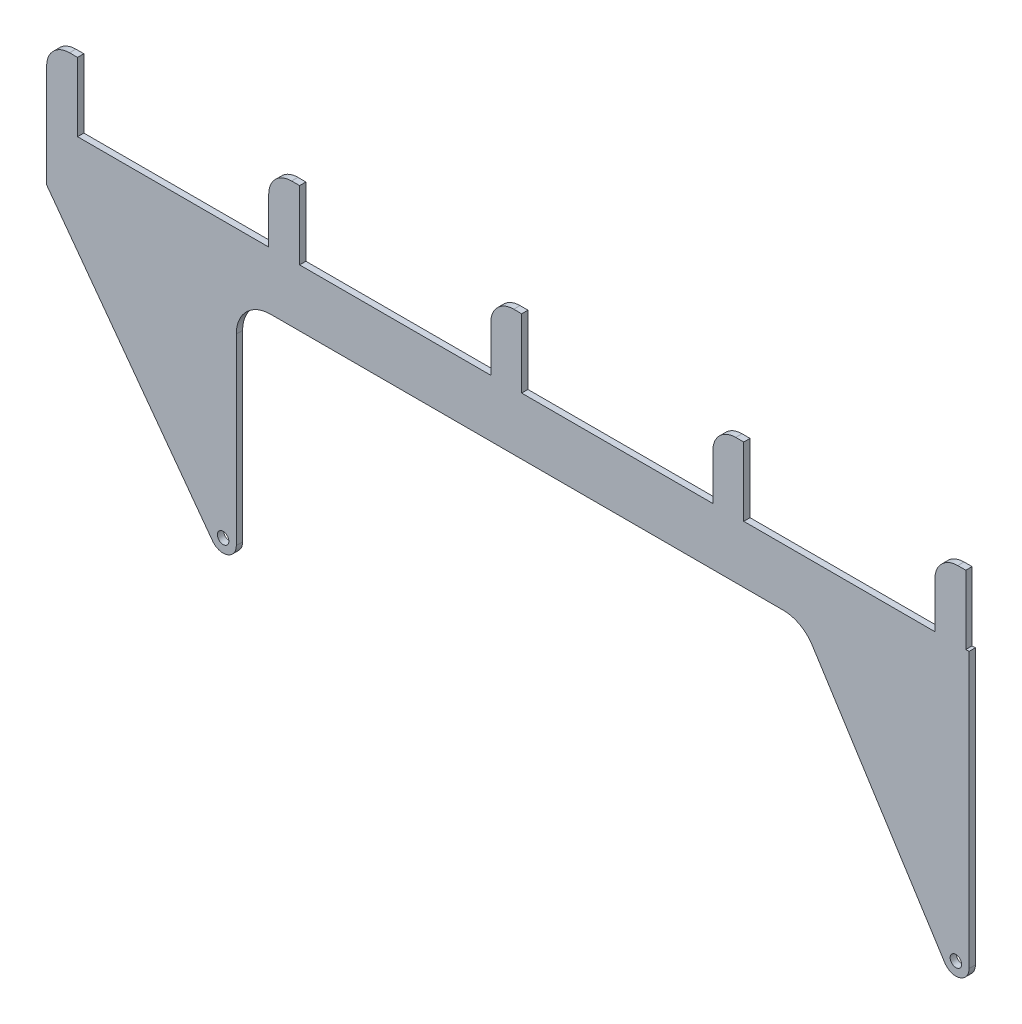
from build123d import *

# Parameters (mm, degrees)
SKETCH1_R           = 5
BOSS_EXTRUDE1_DEPTH = 2.75
FILLET1_R           = 20


with BuildPart() as part:
    # Sketch1 → Boss-Extrude1 (new body, symmetric)
    with BuildSketch(Plane.XY):
        with BuildLine():
            Line((-402.92, 0), (-402.92, 60))
            Line((-402.92, 60), (-375.92, 60))
            Line((-375.92, 60), (-375.92, 0))
            Line((-375.92, 0), (-208.92, 0))
            Line((-208.92, 0), (-208.92, 60))
            Line((-208.92, 60), (-181.92, 60))
            Line((-181.92, 60), (-181.92, 0))
            Line((-181.92, 0), (-14.92, 0))
            Line((-14.92, 0), (-14.92, 60))
            Line((-14.92, 60), (12.08, 60))
            Line((12.08, 60), (12.08, 0))
            Line((12.08, 0), (179.08, 0))
            Line((179.08, 0), (179.08, 60))
            Line((179.08, 60), (206.08, 60))
            Line((206.08, 60), (206.08, 0))
            Line((206.08, 0), (373.08, 0))
            Line((373.08, 0), (373.08, 60))
            Line((373.08, 60), (400.08, 60))
            Line((400.08, 60), (400.08, 0))
            Line((400.08, 0), (402.92, 0))
            Line((402.92, 0), (402.92, -240))
            ThreePointArc((402.92, -240), (394.630398166, -251.042796005), (381.71246198, -246.165525573))
            Line((381.71246198, -246.165525573), (265.960766405, -63.916020245))
            ThreePointArc((265.960766405, -63.916020245), (255.084601896, -53.708181951), (240.636754178, -50))
            Line((240.636754178, -50), (-207.242294627, -50))
            ThreePointArc((-207.242294627, -50), (-228.455498062, -58.786796564), (-237.242294627, -80))
            Line((-237.242294627, -80), (-237.242294627, -240))
            ThreePointArc((-237.242294627, -240), (-245.153860516, -250.925801601), (-258.002840824, -246.81852507))
            Line((-258.002840824, -246.81852507), (-402.92, -50))
            Line((-402.92, -50), (-402.92, 0))
        make_face()
        with Locations((-248.742294627, -240)):
            Circle(SKETCH1_R, mode=Mode.SUBTRACT)
        with Locations((391.42, -240)):
            Circle(SKETCH1_R, mode=Mode.SUBTRACT)
    extrude(amount=BOSS_EXTRUDE1_DEPTH, both=True)

    # Fillet1
    fillet1_edges = [part.edges().sort_by_distance(p)[0] for p in [
        (-402.92, 60, 0),
        (-208.92, 60, 0),
        (-14.92, 60, 0),
        (179.08, 60, 0),
        (373.08, 60, 0),
    ]]
    fillet(fillet1_edges, radius=FILLET1_R)


solid = part.part
